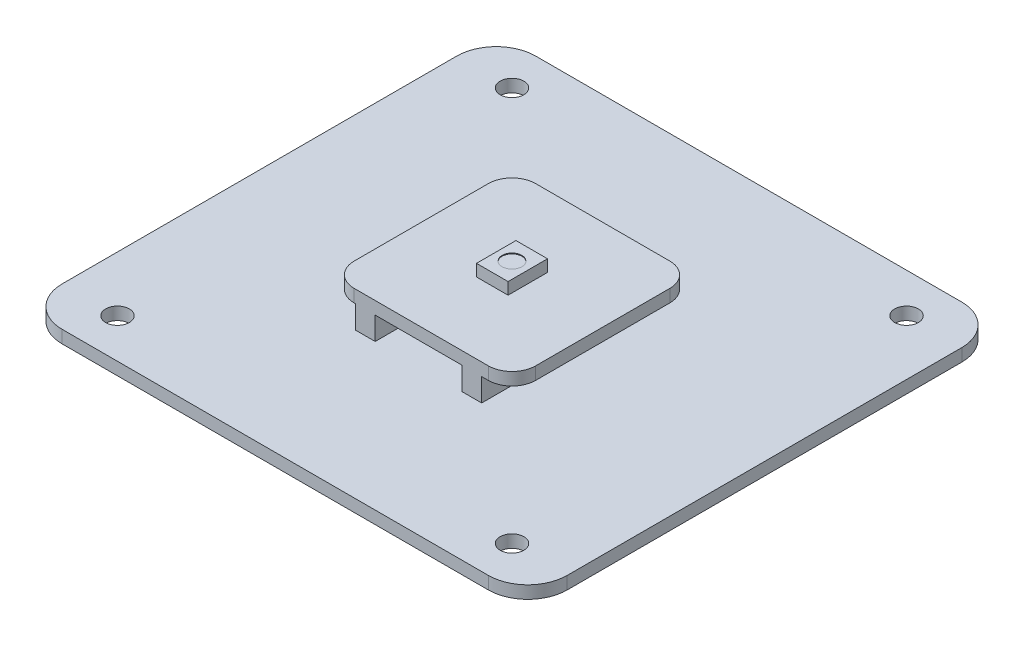
from build123d import *

# Parameters (mm, degrees)
SKETCH1_R           = 1.5
BOSS_EXTRUDE1_DEPTH = 1.6
SKETCH2_W           = 23
SKETCH2_H           = 23
BOSS_EXTRUDE2_DEPTH = 4.5
SKETCH3_W           = 4
SKETCH3_H           = 5
BOSS_EXTRUDE3_DEPTH = 1.5
SKETCH4_W           = 23
SKETCH4_H           = 2.9
CUT_EXTRUDE3_DEPTH  = 39.5
SKETCH5_W           = 2.5
SKETCH5_H           = 2.9
BOSS_EXTRUDE4_DEPTH = 23
FILLET1_R           = 3
SKETCH6_R           = 1.25
CUT_EXTRUDE4_DEPTH  = 0.1


with BuildPart() as part:
    # Sketch1 → Boss-Extrude1 (new body)
    with BuildSketch(Plane(origin=(0, 0, 0), x_dir=(1, 0, 0), z_dir=(0, 1, 0))):
        with BuildLine():
            Line((-27, -30), (27, -30))
            ThreePointArc((27, -30), (30.535533906, -28.535533906), (32, -25))
            Line((32, -25), (32, 25))
            ThreePointArc((32, 25), (30.535533906, 28.535533906), (27, 30))
            Line((27, 30), (-27, 30))
            ThreePointArc((-27, 30), (-30.535533906, 28.535533906), (-32, 25))
            Line((-32, 25), (-32, -25))
            ThreePointArc((-32, -25), (-30.535533906, -28.535533906), (-27, -30))
        make_face()
        with Locations((25, 25)):
            Circle(SKETCH1_R, mode=Mode.SUBTRACT)
        with Locations((-25, 25)):
            Circle(SKETCH1_R, mode=Mode.SUBTRACT)
        with Locations((-25, -25)):
            Circle(SKETCH1_R, mode=Mode.SUBTRACT)
        with Locations((25, -25)):
            Circle(SKETCH1_R, mode=Mode.SUBTRACT)
    extrude(amount=BOSS_EXTRUDE1_DEPTH)

    # Sketch2 → Boss-Extrude2 (add)
    with BuildSketch(Plane(origin=(0, 1.6, 0), x_dir=(1, 0, 0), z_dir=(0, 1, 0))):
        Rectangle(SKETCH2_W, SKETCH2_H)
    extrude(amount=BOSS_EXTRUDE2_DEPTH)

    # Sketch3 → Boss-Extrude3 (add)
    with BuildSketch(Plane(origin=(0, 6.1, 0), x_dir=(1, 0, 0), z_dir=(0, 1, 0))):
        Rectangle(SKETCH3_W, SKETCH3_H)
    extrude(amount=BOSS_EXTRUDE3_DEPTH)

    # Sketch4 → Cut-Extrude3 (cut)
    with BuildSketch(Plane.XY.offset(11.5)):
        with Locations((0, 3.05)):
            Rectangle(SKETCH4_W, SKETCH4_H)
    extrude(amount=-CUT_EXTRUDE3_DEPTH, mode=Mode.SUBTRACT)

    # Sketch5 → Boss-Extrude4 (add)
    with BuildSketch(Plane.XY.offset(11.5)):
        with Locations((-7.09044311, 3.05)):
            Rectangle(SKETCH5_W, SKETCH5_H)
        with Locations((6.40955689, 3.05)):
            Rectangle(SKETCH5_W, SKETCH5_H)
    extrude(amount=-BOSS_EXTRUDE4_DEPTH)

    # Fillet1
    fillet1_edges = [part.edges().sort_by_distance(p)[0] for p in [
        (11.5, 5.3, 11.5),
        (11.5, 5.3, -11.5),
        (-11.5, 5.3, -11.5),
        (-11.5, 5.3, 11.5),
    ]]
    fillet(fillet1_edges, radius=FILLET1_R)

    # Sketch6 → Cut-Extrude4 (cut)
    with BuildSketch(Plane(origin=(0, 7.6, 0), x_dir=(1, 0, 0), z_dir=(0, 1, 0))):
        Circle(SKETCH6_R)
    extrude(amount=-CUT_EXTRUDE4_DEPTH, mode=Mode.SUBTRACT)


solid = part.part
